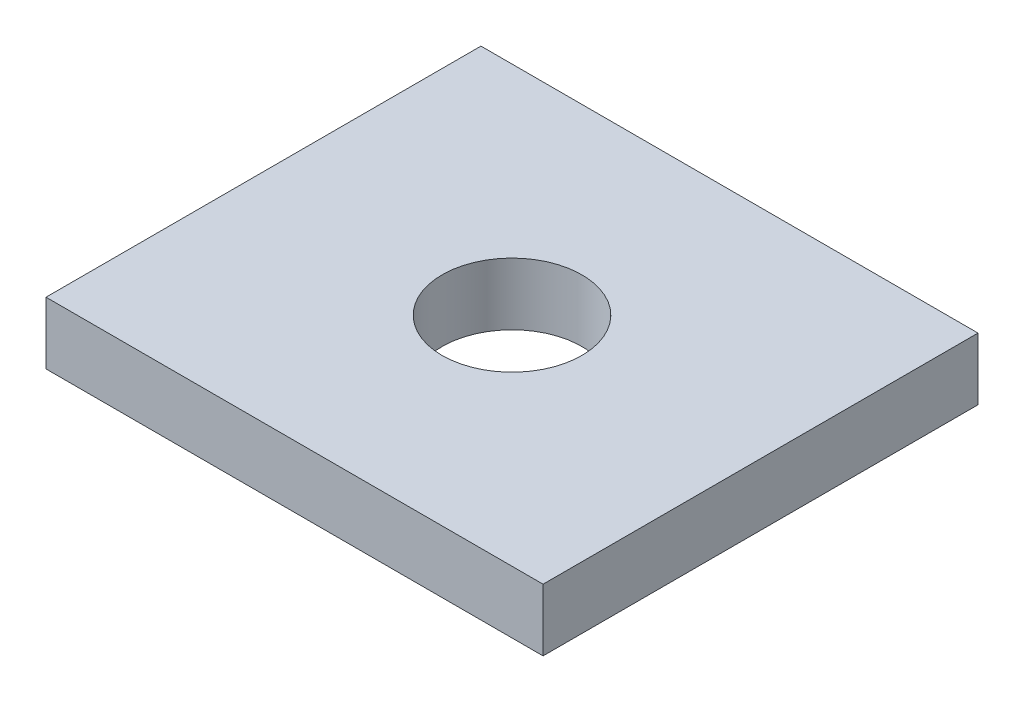
from build123d import *

# Parameters (mm, degrees)
SKETCH1_W          = 25.4
SKETCH1_H          = 22.225
EXTRUDE1_DEPTH     = 1.5875
SKETCH2_R          = 3.571875
CUT_EXTRUDE1_DEPTH = 4.175


with BuildPart() as part:
    # Sketch1 → Extrude1 (new body, symmetric)
    with BuildSketch(Plane(origin=(0, 0, 0), x_dir=(1, 0, 0), z_dir=(0, 1, 0))):
        Rectangle(SKETCH1_W, SKETCH1_H)
    extrude(amount=EXTRUDE1_DEPTH, both=True)

    # Sketch2 → Cut-Extrude1 (cut, through all)
    with BuildSketch(Plane(origin=(0, 1.5875, 0), x_dir=(1, 0, 0), z_dir=(0, 1, 0))):
        Circle(SKETCH2_R)
    extrude(amount=-CUT_EXTRUDE1_DEPTH, mode=Mode.SUBTRACT)


solid = part.part
